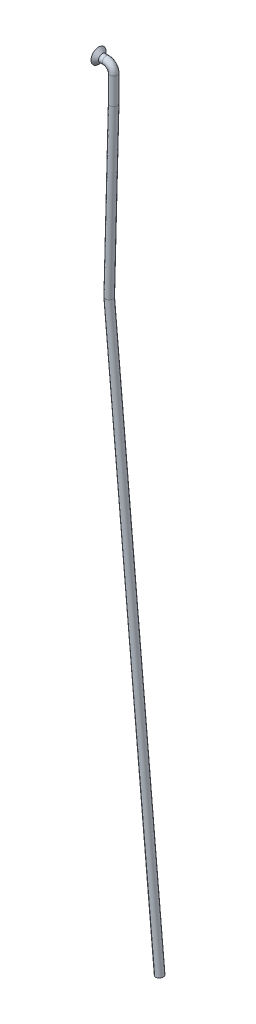
from build123d import *

# Parameters (mm, degrees)
ESQUISSE2_R = 1


with BuildPart() as part:
    # Balayage1: sweep along a path in Esquisse1
    with BuildLine(Plane.XY) as balayage1_path:
        Line((12.194958481, -203.034093166), (-1.177962674, -53.984579624))
        Line((-1.177962674, -53.984579624), (0, -9))
        Line((0, -9), (0, -2))
        ThreePointArc((0, -2), (-0.585786438, -0.585786438), (-2, 0))
        Line((-2, 0), (-4, 0))
    # Esquisse2 → Balayage1 (sweep)
    with BuildSketch(Plane(origin=(-4, 0, 0), x_dir=(0, 0, -1), z_dir=(1, 0, 0))):
        Circle(ESQUISSE2_R)
    sweep(path=balayage1_path.line, transition=Transition.RIGHT)

    # Esquisse3 → Révolution1 (revolve)
    with BuildSketch(Plane.XY):
        Polygon((-4, 1), (-4, 2), (-3, 1), align=None)
    revolve(axis=Axis((0, 0, 0), (-1, 0, 0)))


solid = part.part
